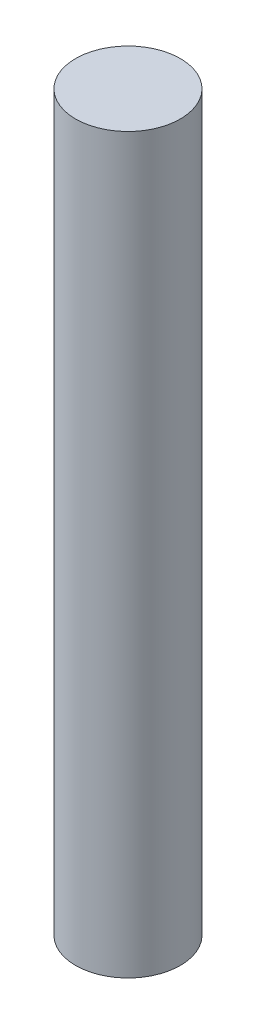
from build123d import *

# Parameters (mm, degrees)
SKETCH2_R           = 12.7
BOSS_EXTRUDE3_DEPTH = 177.8


with BuildPart() as part:
    # Sketch2 → Boss-Extrude3 (new body)
    with BuildSketch(Plane(origin=(0, 0, 0), x_dir=(1, 0, 0), z_dir=(0, 1, 0))):
        Circle(SKETCH2_R)
    extrude(amount=BOSS_EXTRUDE3_DEPTH)


solid = part.part
